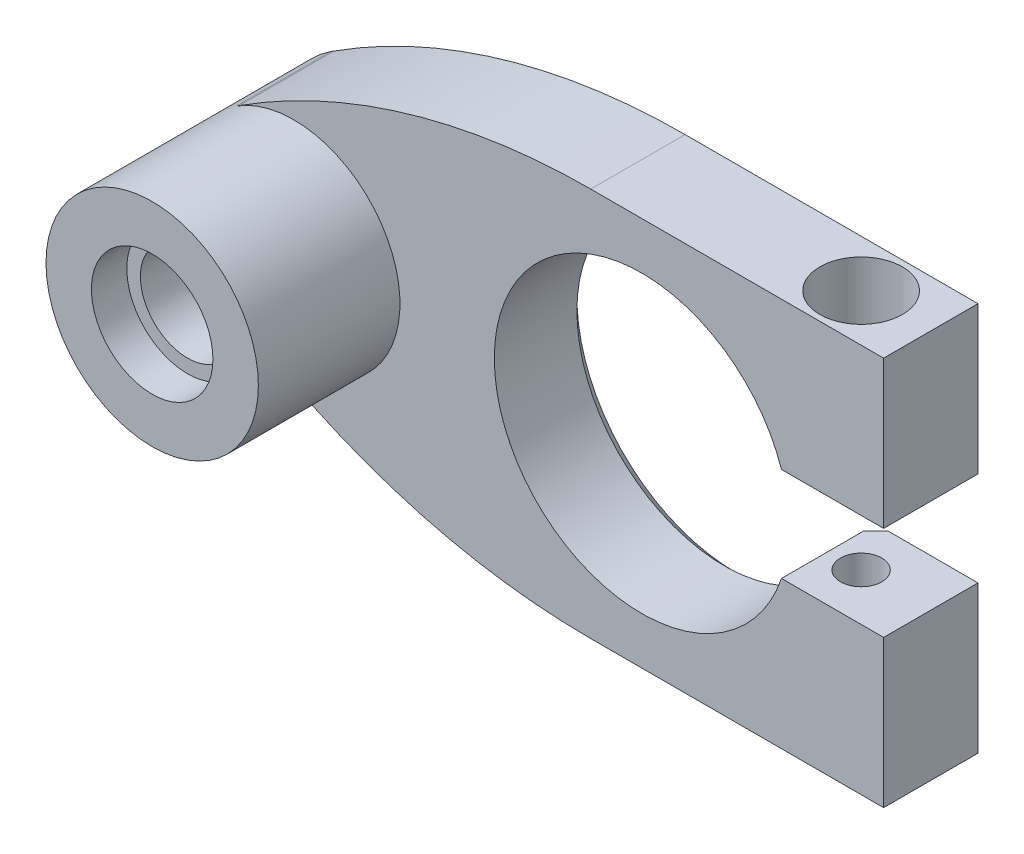
from build123d import *

# Parameters (mm, degrees)
ESBO_O1_R                = 4
RESSALTO_EXTRUS_O1_DEPTH = 20
ESBO_O2_OUTSIDE_W        = 75.1
ESBO_O2_OUTSIDE_H        = 49.1
ESBO_O2_OUTSIDE_R        = 9
CORTE_EXTRUS_O1_DEPTH    = 12
FILETE1_R                = 55
ESBO_O3_R                = 5.15
CORTE_EXTRUS_O2_DEPTH    = 3
CORTE_EXTRUS_O3_START    = -20
ESBO_O3_2_R              = 5.15
CORTE_EXTRUS_O3_DEPTH    = 3
ESBO_O4_R                = 1.75
CORTE_EXTRUS_O4_DEPTH    = 34
CORTE_EXTRUS_O5_DEPTH    = 7
ESBO_O6_R                = 3.5
CORTE_EXTRUS_O6_DEPTH    = 5
CHANFRO1_SIZE            = 1


with BuildPart() as part:
    # Esboço1 → Ressalto-extrusão1 (new body)
    with BuildSketch(Plane.XY):
        with BuildLine():
            Line((-20.5, 16.5), (-34.372611465, 7.566878981))
            ThreePointArc((-34.372611465, 7.566878981), (-38.5, 0), (-34.372611465, -7.566878981))
            Line((-34.372611465, -7.566878981), (-20.5, -16.5))
            Line((-20.5, -16.5), (20.5, -16.5))
            Line((20.5, -16.5), (20.5, -4))
            Line((20.5, -4), (11.842719282, -4))
            ThreePointArc((11.842719282, -4), (-12.5, 0), (11.842719282, 4))
            Line((11.842719282, 4), (20.5, 4))
            Line((20.5, 4), (20.5, 16.5))
            Line((20.5, 16.5), (-20.5, 16.5))
        make_face()
        with Locations((-29.5, 0)):
            Circle(ESBO_O1_R, mode=Mode.SUBTRACT)
    extrude(amount=RESSALTO_EXTRUS_O1_DEPTH)

    # Esboço2 outside → Corte-extrusão1 (cut)
    with BuildSketch(Plane.XY.offset(20)):
        with Locations((-9, 0)):
            Rectangle(ESBO_O2_OUTSIDE_W, ESBO_O2_OUTSIDE_H)
        with Locations((-29.5, 0)):
            Circle(ESBO_O2_OUTSIDE_R, mode=Mode.SUBTRACT)
    extrude(amount=-CORTE_EXTRUS_O1_DEPTH, mode=Mode.SUBTRACT)

    # Filete1
    filete1_edges = [part.edges().sort_by_distance(p)[0] for p in [
        (-20.5, -16.5, 4),
        (-20.5, 16.5, 4),
    ]]
    fillet(filete1_edges, radius=FILETE1_R)

    # Esboço3 → Corte-extrusão2 (cut)
    with BuildSketch(Plane.XY.offset(20)):
        with Locations((-29.5, 0)):
            Circle(ESBO_O3_R)
    extrude(amount=-CORTE_EXTRUS_O2_DEPTH, mode=Mode.SUBTRACT)

    # Esboço3<2> → Corte-extrusão3 (cut)
    with BuildSketch(Plane.XY.offset(20).offset(CORTE_EXTRUS_O3_START)):
        with Locations((-29.5, 0)):
            Circle(ESBO_O3_2_R)
    extrude(amount=CORTE_EXTRUS_O3_DEPTH, mode=Mode.SUBTRACT)

    # Esboço4 → Corte-extrusão4 (cut, through all)
    with BuildSketch(Plane.XZ.offset(16.5)):
        with Locations((14.592719282, 4)):
            Circle(ESBO_O4_R)
    extrude(amount=-CORTE_EXTRUS_O4_DEPTH, mode=Mode.SUBTRACT)

    # Esboço5 → Corte-extrusão5 (cut)
    with BuildSketch(Plane.XZ.offset(16.5)):
        Polygon((14.592719282, 7.233161507), (11.792719282, 5.616580754), (11.792719282, 2.383419246), (14.592719282, 0.766838493), (17.392719282, 2.383419246), (17.392719282, 5.616580754), align=None)
    extrude(amount=-CORTE_EXTRUS_O5_DEPTH, mode=Mode.SUBTRACT)

    # Esboço6 → Corte-extrusão6 (cut)
    with BuildSketch(Plane(origin=(0, 16.5, 0), x_dir=(1, 0, 0), z_dir=(0, 1, 0))):
        with Locations((14.592719282, -4)):
            Circle(ESBO_O6_R)
    extrude(amount=-CORTE_EXTRUS_O6_DEPTH, mode=Mode.SUBTRACT)

    # Chanfro1
    chanfro1_edges = [part.edges().sort_by_distance(p)[0] for p in [
        (-12.5, 0, 0),
        (-34.65, 0, 0),
    ]]
    chamfer(chanfro1_edges, length=CHANFRO1_SIZE)


solid = part.part
